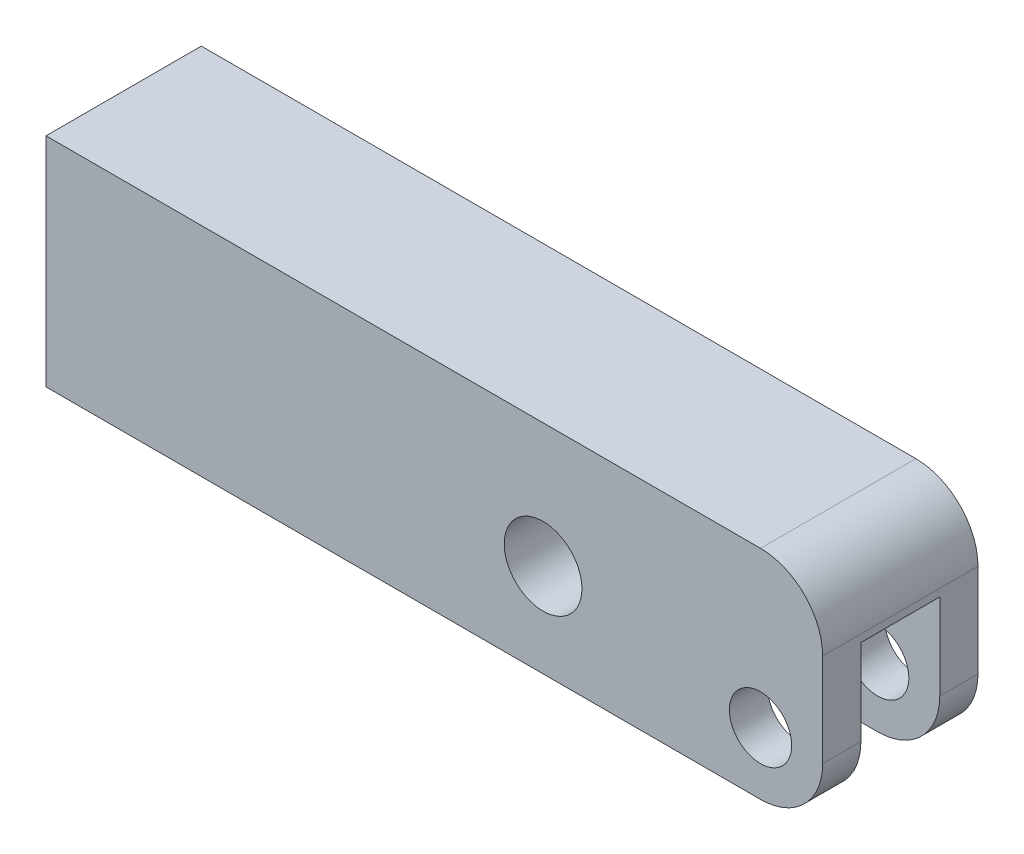
from build123d import *

# Parameters (mm, degrees)
SKETCH11_W         = 158.75
SKETCH11_H         = 44.45
SKETCH11_R         = 6.36905
SKETCH11_R_2       = 7.94385
EXTRUDE3_DEPTH     = 15.875
CUT_EXTRUDE1_DEPTH = 30.226
FILLET1_R          = 12.7


with BuildPart() as part:
    # Sketch11 → Extrude3 (new body, symmetric)
    with BuildSketch(Plane.XY):
        with Locations((-66.675, 9.525)):
            Rectangle(SKETCH11_W, SKETCH11_H)
        Circle(SKETCH11_R, mode=Mode.SUBTRACT)
        with Locations((-44.45, 6.35)):
            Circle(SKETCH11_R_2, mode=Mode.SUBTRACT)
    extrude(amount=EXTRUDE3_DEPTH, both=True)

    # Sketch12 → Cut-Extrude1 (cut)
    with BuildSketch(Plane.XZ.offset(12.7)):
        with BuildLine():
            Line((-17.526, 8.0645), (12.7, 8.0645))
            Line((12.7, 8.0645), (12.7, -8.0645))
            Line((12.7, -8.0645), (-17.526, -8.0645))
            ThreePointArc((-17.526, -8.0645), (-25.5905, 0), (-17.526, 8.0645))
        make_face()
    extrude(amount=-CUT_EXTRUDE1_DEPTH, mode=Mode.SUBTRACT)

    # Fillet1
    fillet1_edges = [part.edges().sort_by_distance(p)[0] for p in [
        (12.7, -12.7, -11.96975),
        (12.7, 31.75, 0),
        (12.7, -12.7, 11.96975),
    ]]
    fillet(fillet1_edges, radius=FILLET1_R)


solid = part.part
